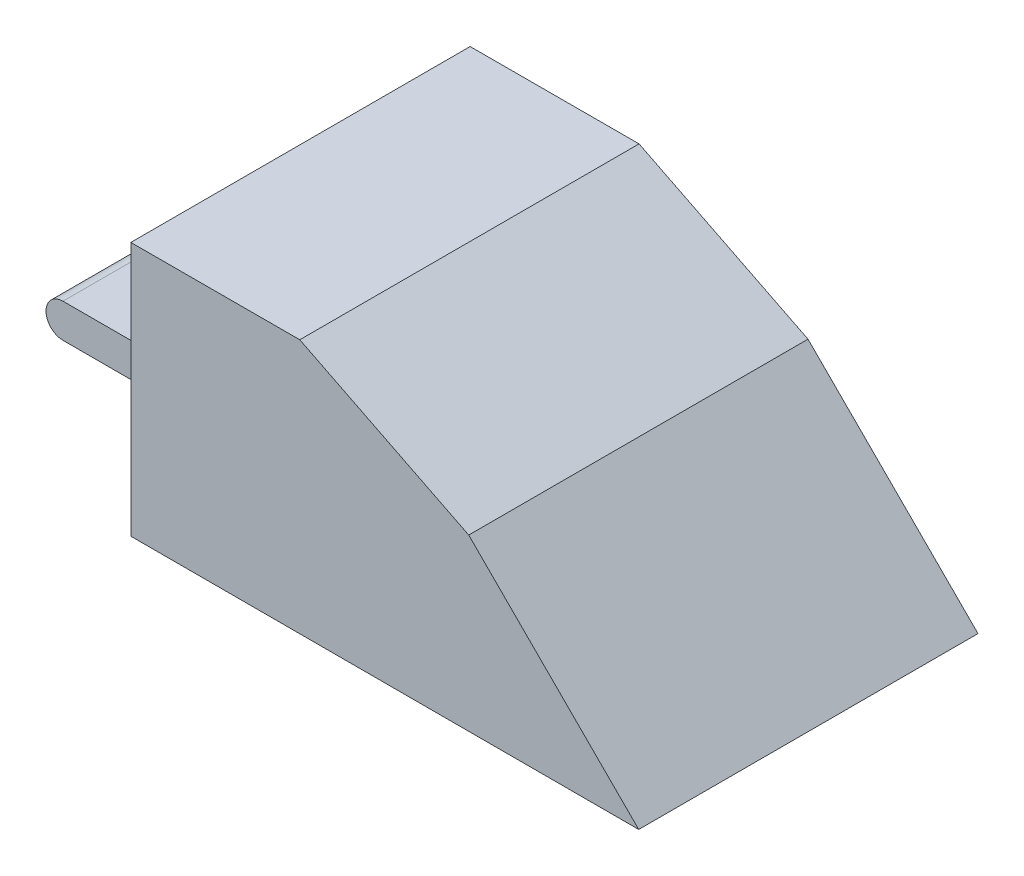
from build123d import *

# Parameters (mm, degrees)
SKETCH_1_W          = 40
SKETCH_1_H          = 20
EXTRUDE_1_DEPTH     = 20
SKETCH_2_W          = 8
SKETCH_2_H          = 4
EXTRUDE_2_DEPTH     = 10
CUT_EXTRUDE_8_DEPTH = 20
SKETCH_13_R         = 1
EXTRUDE_5_DEPTH     = 8
CUT_EXTRUDE_9_DEPTH = 20


with BuildPart() as part:
    # 草图1 → 凸台-拉伸1 (new body)
    with BuildSketch(Plane(origin=(0, 0, 0), x_dir=(1, 0, 0), z_dir=(0, 1, 0))):
        with Locations((18, 0)):
            Rectangle(SKETCH_1_W, SKETCH_1_H)
    extrude(amount=EXTRUDE_1_DEPTH)

    # 草图2 → 凸台-拉伸2 (add)
    with BuildSketch(Plane.ZY.offset(2)):
        with Locations((0, 2)):
            Rectangle(SKETCH_2_W, SKETCH_2_H)
    extrude(amount=EXTRUDE_2_DEPTH)

    # 草图12 → 切除-拉伸8 (cut)
    with BuildSketch(Plane.XY.offset(4)):
        with BuildLine():
            Line((-5, 2), (-18.474771325, 2))
            Line((-18.474771325, 2), (-18.474771325, 0))
            Line((-18.474771325, 0), (-5, 0))
            ThreePointArc((-5, 0), (-6, 1), (-5, 2))
        make_face()
    extrude(amount=-CUT_EXTRUDE_8_DEPTH, mode=Mode.SUBTRACT)

    # 草图13 → 凸台-拉伸5 (add)
    with BuildSketch(Plane.XY.offset(4)):
        with Locations((-12, 3)):
            Circle(SKETCH_13_R)
    extrude(amount=-EXTRUDE_5_DEPTH)

    # 草图14 → 切除-拉伸9 (cut)
    with BuildSketch(Plane.XY.offset(10)):
        Polygon((40.736846826, 20.947387303), (-2, 20), (-2, 15), (7.959394399, 15.0101514), (17.918788798, 10.020302801), (27.939091598, 0), (43.275764459, 0), align=None)
    extrude(amount=-CUT_EXTRUDE_9_DEPTH, mode=Mode.SUBTRACT)


solid = part.part
